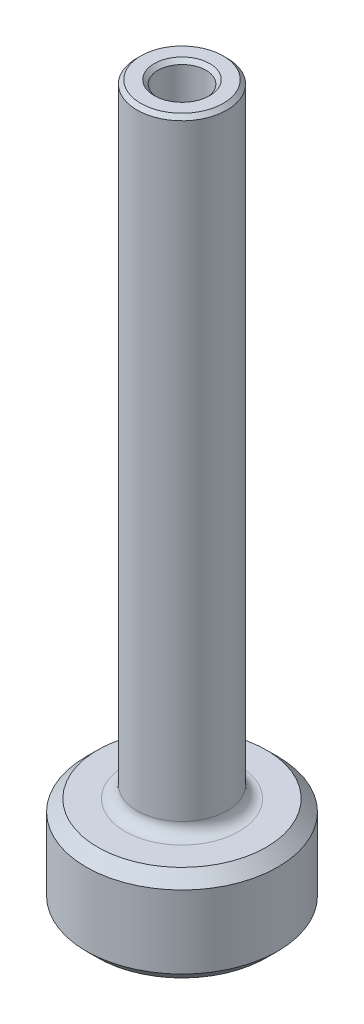
from build123d import *

# Parameters (mm, degrees)
CUT_EXTRUDE1_DEPTH = 3.175
FILLET1_R          = 0.79375
CHAMFER1_SIZE      = 0.254
CHAMFER2_SIZE      = 0.762


with BuildPart() as part:
    # Sketch1 → Revolve1 (revolve)
    with BuildSketch(Plane.XY):
        Polygon((3.175, 0), (6.35, 0), (6.35, 6.35), (2.9845, 6.35), (2.9845, 47.625), (1.5875, 47.625), (1.5875, 3.175), (3.175, 3.175), align=None)
    revolve(axis=Axis((0, 5.569325848, 0), (0, -1, 0)))

    # Sketch2 → Cut-Extrude1 (cut)
    with BuildSketch(Plane.XZ):
        Polygon((1.833087105, 3.175), (-1.833087105, 3.175), (-3.666174209, 0), (-1.833087105, -3.175), (1.833087105, -3.175), (3.666174209, 0), align=None)
    extrude(amount=-CUT_EXTRUDE1_DEPTH, mode=Mode.SUBTRACT)

    # Fillet1
    fillet1_edges = [part.edges().sort_by_distance(p)[0] for p in [
        (0, 3.175, 3.175),
        (-2.749630657, 3.175, 1.5875),
        (-2.749630657, 3.175, -1.5875),
        (0, 3.175, -3.175),
        (2.749630657, 3.175, -1.5875),
        (2.749630657, 3.175, 1.5875),
        (-1.833087105, 1.5875, 3.175),
        (-3.666174209, 1.5875, 0),
        (-1.833087105, 1.5875, -3.175),
        (1.833087105, 1.5875, -3.175),
        (3.666174209, 1.5875, 0),
        (1.833087105, 1.5875, 3.175),
        (-2.9845, 6.35, 0),
    ]]
    fillet(fillet1_edges, radius=FILLET1_R)

    # Chamfer1
    chamfer1_edges = [part.edges().sort_by_distance(p)[0] for p in [
        (-1.5875, 3.175, 0),
        (0, 0, 3.175),
        (2.749630657, 0, 1.5875),
        (-1.5875, 47.625, 0),
        (2.749630657, 0, -1.5875),
        (0, 0, -3.175),
        (-2.9845, 47.625, 0),
        (-2.749630657, 0, -1.5875),
        (-2.749630657, 0, 1.5875),
        (-1.771690329, 0, 3.068657664),
        (1.771690329, 0, 3.068657664),
        (3.543380657, 0, 0),
        (1.771690329, 0, -3.068657664),
        (-1.771690329, 0, -3.068657664),
        (-3.543380657, 0, 0),
    ]]
    chamfer(chamfer1_edges, length=CHAMFER1_SIZE)

    # Chamfer2
    chamfer2_edges = [part.edges().sort_by_distance(p)[0] for p in [
        (-6.35, 6.35, 0),
        (-6.35, 0, 0),
    ]]
    chamfer(chamfer2_edges, length=CHAMFER2_SIZE)


solid = part.part
